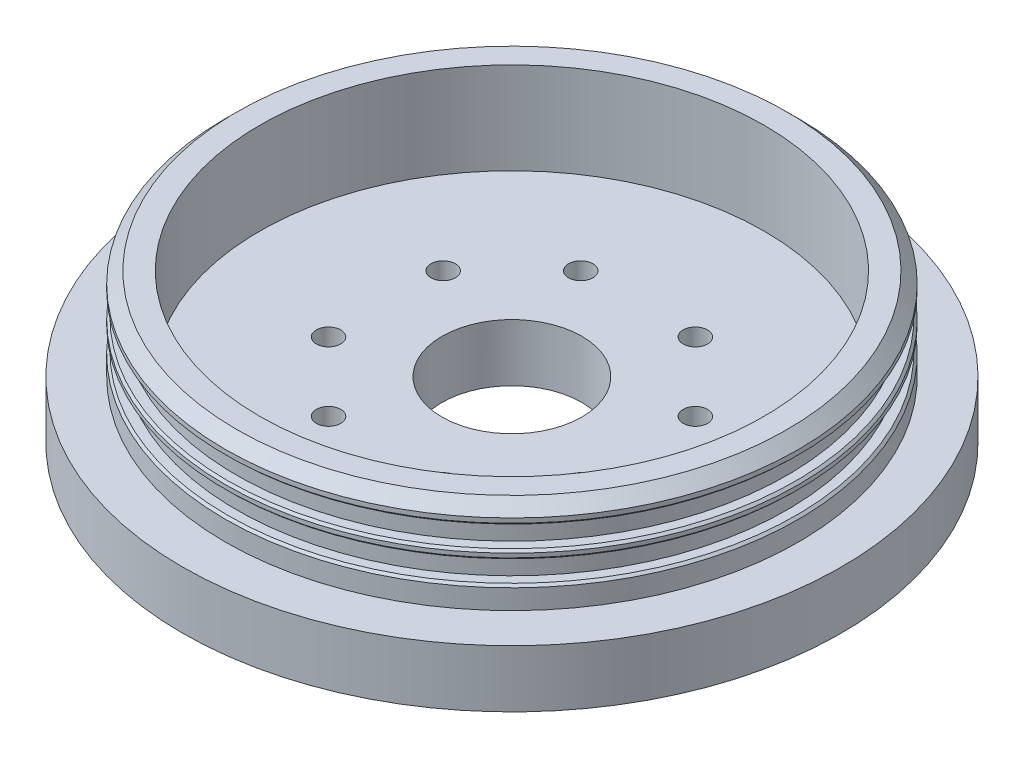
from build123d import *

# Parameters (mm, degrees)
EXTRUDE1_DEPTH                       = 3.175
EXTRUDE1_DEPTH_BACK                  = 3.175
SKETCH1_R                            = 36.5125
SKETCH2_R                            = 31.75
EXTRUDE2_DEPTH                       = 10.16
SKETCH4_W                            = 1.27
SKETCH4_H                            = 2.3622
SKETCH5_R                            = 27.94
CUT_EXTRUDE1_DEPTH                   = 10.16
CHAMFER1_SIZE                        = 1.27
CHAMFER2_SIZE                        = 0.254
TAP_DRILL_FOR_6_TAP1_D               = 2.7051
TAP_DRILL_FOR_6_TAP1_DEPTH           = 3.302
TAP_DRILL_FOR_6_TAP1_TIP             = 0.81269403
TAP_DRILL_FOR_6_TAP1_ON_FACE_2_D     = 2.7051
TAP_DRILL_FOR_6_TAP1_ON_FACE_2_DEPTH = 3.302
TAP_DRILL_FOR_6_TAP1_ON_FACE_2_TIP   = 0.81269403


with BuildPart() as part:
    # Sketch1 → Extrude1 (new, two sides: drawn at the far end of the back side and taken through both)
    with BuildSketch(Plane(origin=(0, 0, 0), x_dir=(1, 0, 0), z_dir=(0, 1, 0)).offset(-EXTRUDE1_DEPTH_BACK)):
        Circle(SKETCH1_R)
    extrude(amount=EXTRUDE1_DEPTH + EXTRUDE1_DEPTH_BACK)

    # Sketch2 → Extrude2 (add)
    with BuildSketch(Plane(origin=(0, 3.175, 0), x_dir=(-1, 0, 0), z_dir=(0, 1, 0))):
        Circle(SKETCH2_R)
    extrude(amount=EXTRUDE2_DEPTH)

    # Sketch4 → Cut-Revolve7 (revolve, cut)
    with BuildSketch(Plane(origin=(0, 0, 0), x_dir=(0, 0, -1), z_dir=(1, 0, 0))):
        with Locations((-31.115, 10.122310801)):
            Rectangle(SKETCH4_W, SKETCH4_H)
        with Locations((-31.115, 6.799968424)):
            Rectangle(SKETCH4_W, SKETCH4_H)
    revolve(axis=Axis((0, -3.175, 0), (0, 1, 0)), mode=Mode.SUBTRACT)

    # Sketch5 → Cut-Extrude1 (cut)
    with BuildSketch(Plane(origin=(0, 13.335, 0), x_dir=(-1, 0, 0), z_dir=(0, 1, 0))):
        Circle(SKETCH5_R)
    extrude(amount=-CUT_EXTRUDE1_DEPTH, mode=Mode.SUBTRACT)

    # Chamfer1
    chamfer1_edges = [part.edges().sort_by_distance(p)[0] for p in [
        (31.75, 13.335, 0),
    ]]
    chamfer(chamfer1_edges, length=CHAMFER1_SIZE)

    # Sketch9 → M14 Clearance Hole1 (revolve, cut)
    with BuildSketch(Plane(origin=(0, -3.175, 0), x_dir=(0, 0, -1), z_dir=(1, 0, 0))):
        Polygon((0, 0), (0, 334.856669797), (7.75, 330.2), (7.75, 0), align=None)
    revolve(axis=Axis((0, -9.525, 0), (0, 1, 0)), mode=Mode.SUBTRACT)

    # Chamfer2
    chamfer2_edges = [part.edges().sort_by_distance(p)[0] for p in [
        (31.75, 11.303410801, 0),
        (31.75, 5.618868424, 0),
        (31.75, 7.981068424, 0),
        (31.75, 8.941210801, 0),
    ]]
    chamfer(chamfer2_edges, length=CHAMFER2_SIZE)

    # Tap Drill for _6 Tap1
    with Locations(Plane(origin=(-6.35, 3.175, 13.97), x_dir=(0, 0, 1), z_dir=(0, 1, 0))):
        with Locations((0, 0), (0, 12.7), (-7.62, 20.32), (-20.32, 20.32), (-27.94, 12.7), (-27.94, 0), (-20.32, -7.62), (-7.62, -7.62), (-13.97, 6.35)):
            Hole(TAP_DRILL_FOR_6_TAP1_D / 2, depth=TAP_DRILL_FOR_6_TAP1_DEPTH)
            with Locations((0, 0, -(TAP_DRILL_FOR_6_TAP1_DEPTH + TAP_DRILL_FOR_6_TAP1_TIP / 2))):  # 118° drill point
                Cone(0, TAP_DRILL_FOR_6_TAP1_D / 2, TAP_DRILL_FOR_6_TAP1_TIP, mode=Mode.SUBTRACT)

    # Tap Drill for _6 Tap1 on face 2
    with Locations(Plane.ZX):
        with Locations((0, 0)):
            Hole(TAP_DRILL_FOR_6_TAP1_ON_FACE_2_D / 2, depth=TAP_DRILL_FOR_6_TAP1_ON_FACE_2_DEPTH)
            with Locations((0, 0, -(TAP_DRILL_FOR_6_TAP1_ON_FACE_2_DEPTH + TAP_DRILL_FOR_6_TAP1_ON_FACE_2_TIP / 2))):  # 118° drill point
                Cone(0, TAP_DRILL_FOR_6_TAP1_ON_FACE_2_D / 2, TAP_DRILL_FOR_6_TAP1_ON_FACE_2_TIP, mode=Mode.SUBTRACT)


solid = part.part
